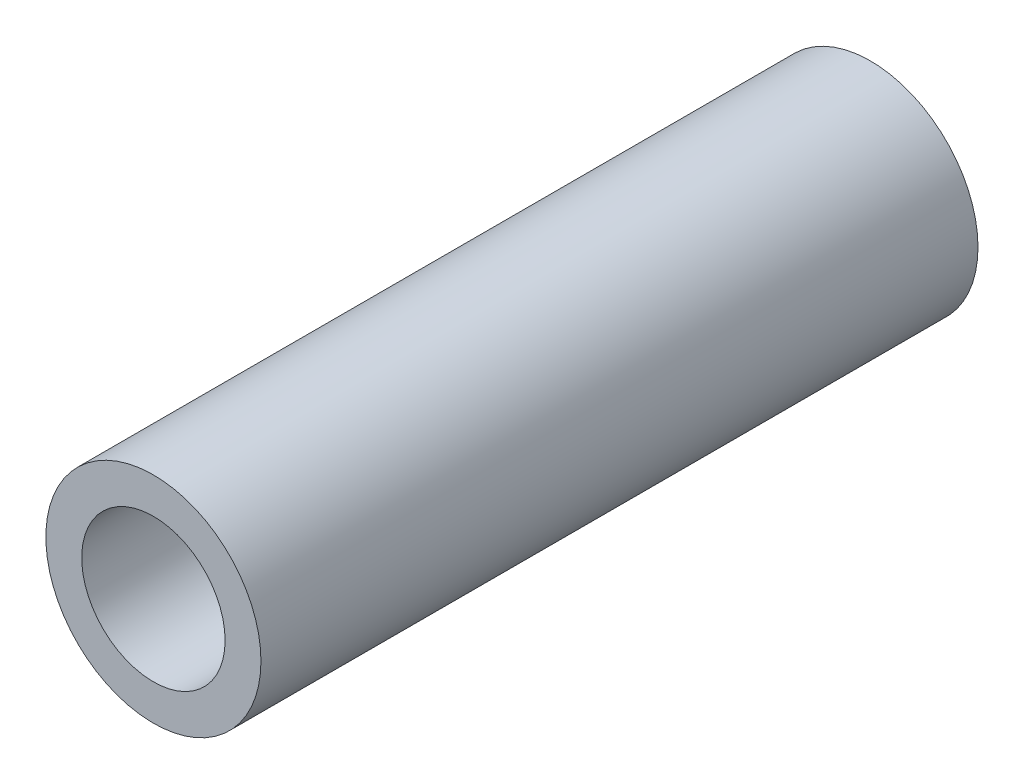
from build123d import *

# Parameters (mm, degrees)
SKETCH1_R           = 3
SKETCH1_R_2         = 2
BOSS_EXTRUDE1_DEPTH = 20


with BuildPart() as part:
    # Sketch1 → Boss-Extrude1 (new body)
    with BuildSketch(Plane.XY):
        Circle(SKETCH1_R)
        Circle(SKETCH1_R_2, mode=Mode.SUBTRACT)
    extrude(amount=BOSS_EXTRUDE1_DEPTH)


solid = part.part
